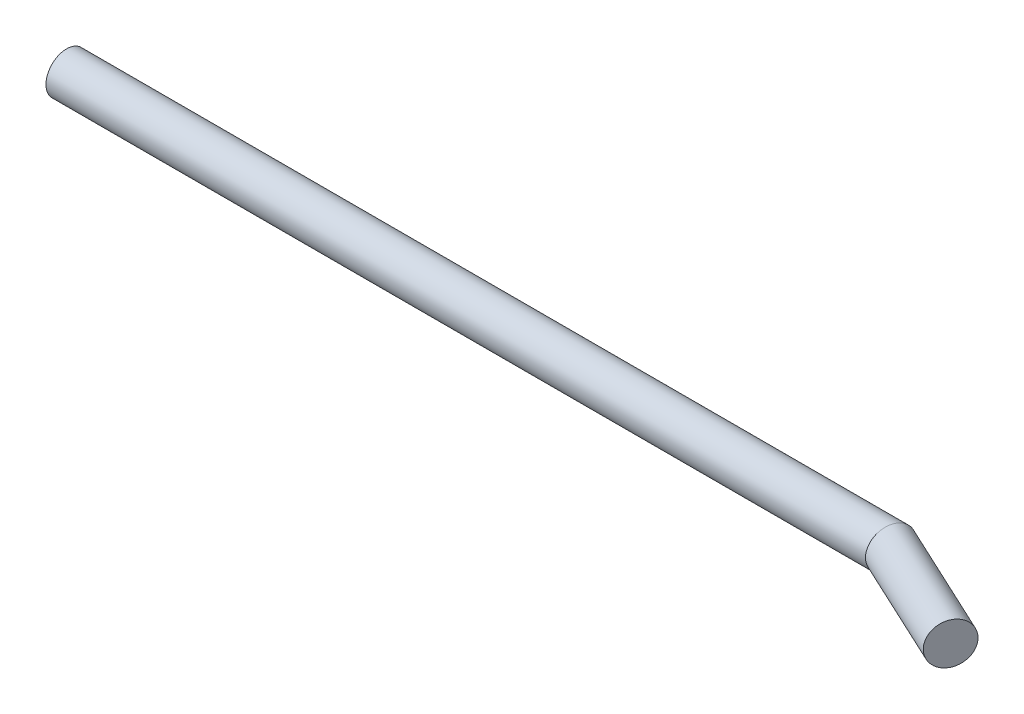
from build123d import *

# Parameters (mm, degrees)
CROQUIS3_R = 5.5


with BuildPart() as part:
    # Barrer1: sweep along a path in Croquis1
    with BuildLine(Plane(origin=(0, 0, 0), x_dir=(1, 0, 0), z_dir=(0, 1, 0))) as barrer1_path:
        Line((-220, 0), (0, 0))
        Line((0, 0), (30, -13.989229745))
    # Croquis3 → Barrer1 (sweep)
    with BuildSketch(Plane(origin=(0, 0, 0), x_dir=(0, 0, -1), z_dir=(1, 0, 0))):
        Circle(CROQUIS3_R)
    sweep(path=barrer1_path.line, transition=Transition.RIGHT)


solid = part.part
